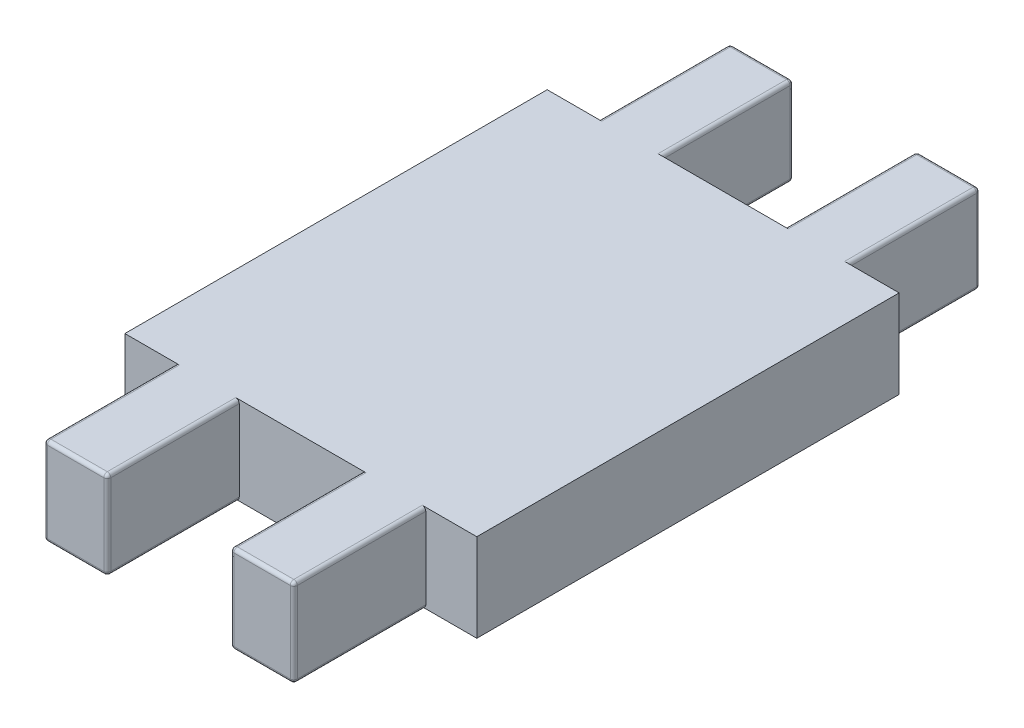
from build123d import *

# Parameters (mm, degrees)
SKETCH1_W               = 20
SKETCH1_H               = 24
BOSS_EXTRUDE1_DEPTH     = 2.5
SKETCH2_W               = 3.6
SKETCH2_H               = 7.5
BOSS_EXTRUDE2_DEPTH     = 5
MIRROR2_COPY_1_SKETCH_W = 3.6
MIRROR2_COPY_1_SKETCH_H = 7.5
MIRROR2_COPY_1_DEPTH    = 5
FILLET1_R               = 0.2
SCALE1_SCALE            = 0.3


with BuildPart() as part:
    # Sketch1 → Boss-Extrude1 (new body, symmetric)
    with BuildSketch(Plane(origin=(0, 0, 0), x_dir=(1, 0, 0), z_dir=(0, 1, 0))):
        Rectangle(SKETCH1_W, SKETCH1_H)
    extrude(amount=BOSS_EXTRUDE1_DEPTH, both=True)

    # Sketch2 → Boss-Extrude2 (add)
    with BuildSketch(Plane(origin=(0, 2.5, 0), x_dir=(1, 0, 0), z_dir=(0, 1, 0))):
        with Locations((-5.3, -15.75)):
            Rectangle(SKETCH2_W, SKETCH2_H)
    boss_extrude2 = extrude(amount=-BOSS_EXTRUDE2_DEPTH)

    # Mirror1: Boss-Extrude2 across plane
    add(boss_extrude2.mirror(Plane(origin=(0, 0, 0), x_dir=(0, 0, 1), z_dir=(1, 0, 0))))

    # Mirror2: Boss-Extrude2 across plane
    add(boss_extrude2.mirror(Plane.XY))

    # Mirror2 copy 1 sketch → Mirror2 copy 1 (add)
    with BuildSketch(Plane(origin=(0, 2.5, 0), x_dir=(-1, 0, 0), z_dir=(0, 1, 0))):
        with Locations((-5.3, -15.75)):
            Rectangle(MIRROR2_COPY_1_SKETCH_W, MIRROR2_COPY_1_SKETCH_H)
    extrude(amount=-MIRROR2_COPY_1_DEPTH)

    # Fillet1
    fillet1_edges = [part.edges().sort_by_distance(p)[0] for p in [
        (-7.1, -2.5, 15.75),
        (-7.1, 0, 19.5),
        (-3.5, -2.5, 15.75),
        (-5.3, -2.5, 19.5),
        (-3.5, 0, 19.5),
        (-7.1, 2.5, 15.75),
        (-5.3, 2.5, 19.5),
        (-3.5, 2.5, 15.75),
        (7.1, 2.5, 15.75),
        (5.3, 2.5, 19.5),
        (7.1, 0, 19.5),
        (3.5, 2.5, 15.75),
        (3.5, 0, 19.5),
        (7.1, -2.5, 15.75),
        (5.3, -2.5, 19.5),
        (3.5, -2.5, 15.75),
        (-7.1, 2.5, -15.75),
        (-5.3, 2.5, -19.5),
        (-7.1, 0, -19.5),
        (-3.5, 2.5, -15.75),
        (-3.5, 0, -19.5),
        (-7.1, -2.5, -15.75),
        (-5.3, -2.5, -19.5),
        (-3.5, -2.5, -15.75),
        (7.1, -2.5, -15.75),
        (7.1, 0, -19.5),
        (3.5, -2.5, -15.75),
        (5.3, -2.5, -19.5),
        (3.5, 0, -19.5),
        (7.1, 2.5, -15.75),
        (5.3, 2.5, -19.5),
        (3.5, 2.5, -15.75),
    ]]
    fillet(fillet1_edges, radius=FILLET1_R)


with BuildPart() as part_1:
    # Scale1: scaled about (0, 0, 0)
    add(part.part.scale(SCALE1_SCALE))


solid = part_1.part
